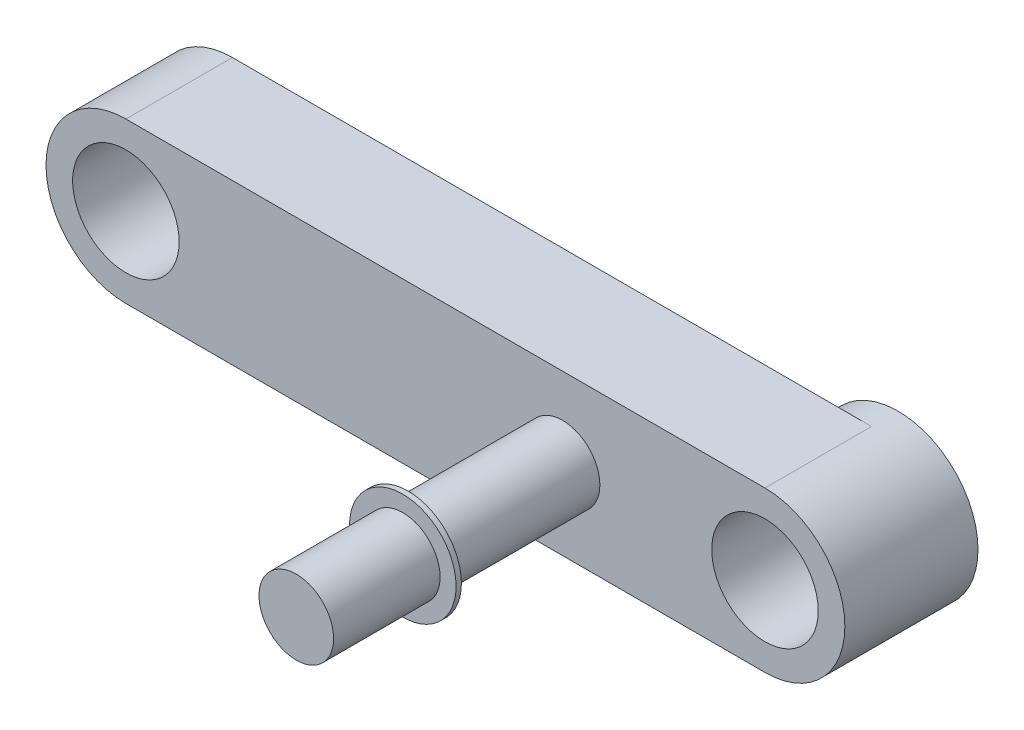
from build123d import *

# Parameters (mm, degrees)
SKETCH_1_R      = 1
EXTRUDE_1_DEPTH = 2
SKETCH_2_R      = 1.5
SKETCH_2_R_2    = 1
EXTRUDE_2_DEPTH = 0.5
SKETCH_3_R      = 0.7
EXTRUDE_3_DEPTH = 5
EXTRUDE_START   = -2
SKETCH_4_R      = 1
EXTRUDE_4_DEPTH = 0.1


with BuildPart() as part:
    # 草图1 → 凸台-拉伸1 (new body)
    with BuildSketch(Plane.XY):
        with BuildLine():
            Line((0, -1.5), (-12, -1.5))
            ThreePointArc((-12, -1.5), (-13.5, 0), (-12, 1.5))
            Line((-12, 1.5), (0, 1.5))
            ThreePointArc((0, 1.5), (1.5, 0), (0, -1.5))
        make_face()
        with Locations((-12, 0)):
            Circle(SKETCH_1_R, mode=Mode.SUBTRACT)
        Circle(SKETCH_1_R, mode=Mode.SUBTRACT)
    extrude(amount=EXTRUDE_1_DEPTH)

    # 草图2 → 凸台-拉伸2 (add)
    with BuildSketch(Plane.XY):
        Circle(SKETCH_2_R)
        Circle(SKETCH_2_R_2, mode=Mode.SUBTRACT)
    extrude(amount=-EXTRUDE_2_DEPTH)

    # 草图3 → 凸台-拉伸3 (add)
    with BuildSketch(Plane.XY.offset(2)):
        with Locations((-3.8, 0)):
            Circle(SKETCH_3_R)
    extrude(amount=EXTRUDE_3_DEPTH)

    # 草图4 → 凸台-拉伸4 (add)
    with BuildSketch(Plane.XY.offset(7).offset(EXTRUDE_START)):
        with Locations((-3.8, 0)):
            Circle(SKETCH_4_R)
    extrude(amount=-EXTRUDE_4_DEPTH)


solid = part.part
